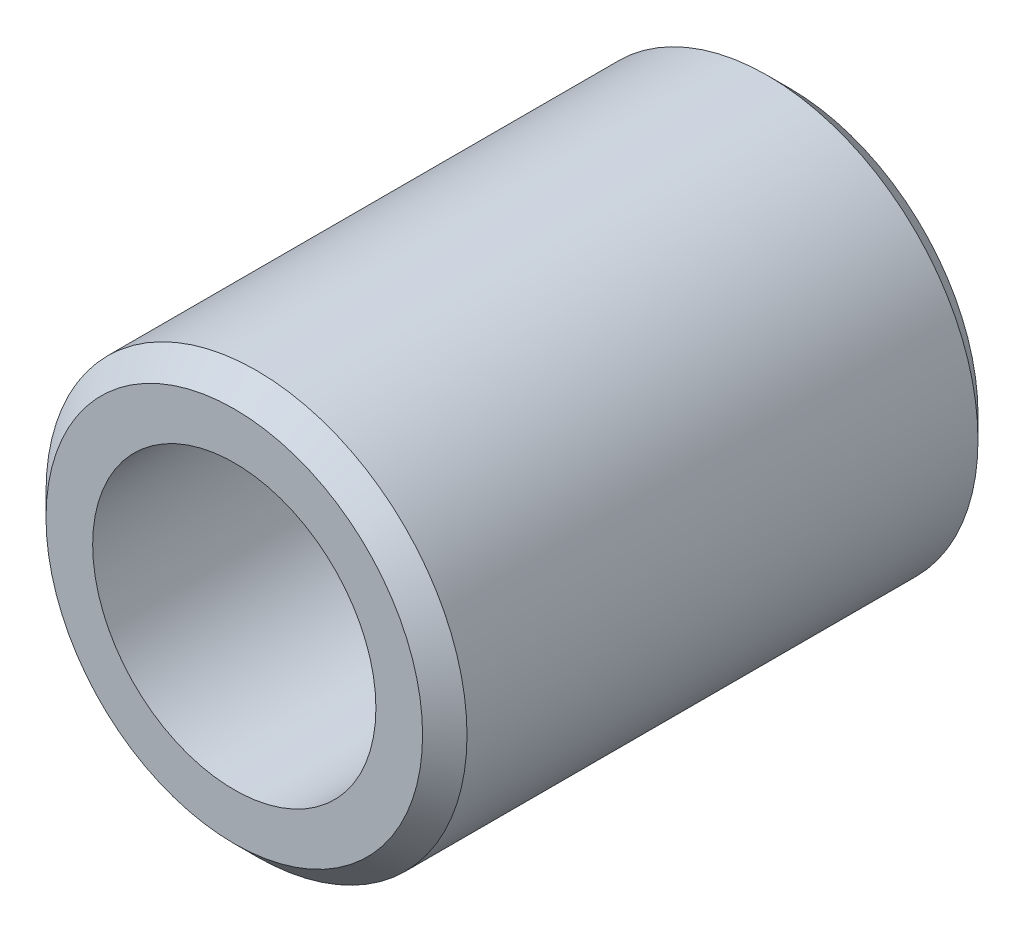
from build123d import *


with BuildPart() as part:
    # Sketch1 → Revolve1 (revolve)
    with BuildSketch(Plane(origin=(0, 0, 0), x_dir=(0, 0, -1), z_dir=(1, 0, 0))):
        Polygon((-3.175, 1.61925), (3.175, 1.61925), (3.175, 2.15265), (2.921, 2.40665), (-2.921, 2.40665), (-3.175, 2.15265), align=None)
    revolve(axis=Axis((0, 0, -3.175), (0, 0, 1)))


solid = part.part
